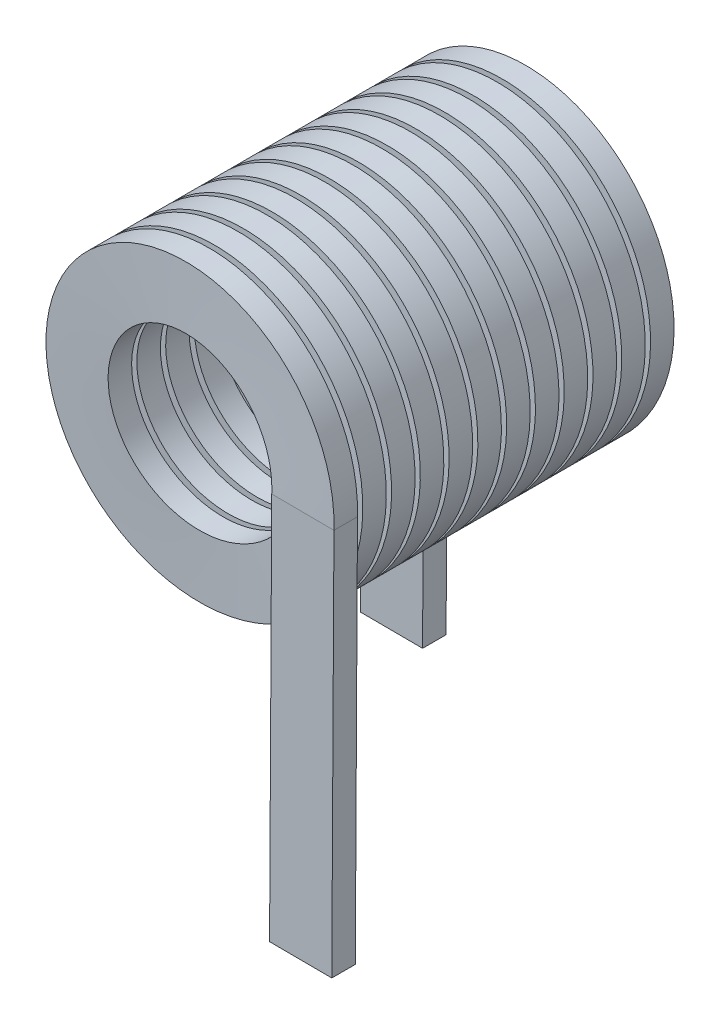
from build123d import *

# Parameters (mm, degrees)
SWEEP2_PITCH        = 3.7592
SWEEP2_HEIGHT       = 43.2308
SWEEP2_RADIUS       = 15.6845
SWEEP2_START_ANGLE  = -180
SKETCH3_W           = 8.128
SKETCH3_H           = 3.0734
BOSS_EXTRUDE1_DEPTH = 50.8
SKETCH4_W           = 8.128
SKETCH4_H           = 3.0734
BOSS_EXTRUDE2_DEPTH = 50.8


with BuildPart() as part:
    # Sweep2: sweep along a helix
    with BuildLine() as sweep2_path:
        add(Helix(SWEEP2_PITCH, SWEEP2_HEIGHT, SWEEP2_RADIUS, center=(0, 0, 0), direction=(0, 0, 1), lefthand=True, mode=Mode.PRIVATE).rotate(Axis((0, 0, 0), (0, 0, 1)), SWEEP2_START_ANGLE))
    # 3DSketch4 → Sweep2 (sweep)
    with BuildSketch(Plane(origin=(19.748248584, 0.087883104, 41.690747617), x_dir=(-0.935364679599574, 0, 0.35368476947358946), z_dir=(0, 1, 0))):
        Polygon((0, 0), (1.087014771, 2.874749806), (8.689658886, 0), (7.602644116, -2.874749806), align=None)
    sweep(path=sweep2_path.line, is_frenet=True)

    # Sketch3 → Boss-Extrude1 (add)
    with BuildSketch(Plane(origin=(-0.000492425, -0.087881724, 0), x_dir=(0.999984302077162, -0.005603177603034767, 0), z_dir=(-0.005603177603034767, -0.999984302077162, 0))):
        with Locations((-15.684248584, -1.1e-08)):
            Rectangle(SKETCH3_W, SKETCH3_H)
    extrude(amount=BOSS_EXTRUDE1_DEPTH)

    # Sketch4 → Boss-Extrude2 (add)
    with BuildSketch(Plane(origin=(0.000492425, 0.087881724, 0), x_dir=(0.999984302077162, -0.005603177603034642, 0), z_dir=(-0.005603177603034642, -0.999984302077162, 0))):
        with Locations((15.684248584, 43.230799989)):
            Rectangle(SKETCH4_W, SKETCH4_H)
    extrude(amount=BOSS_EXTRUDE2_DEPTH)


solid = part.part
